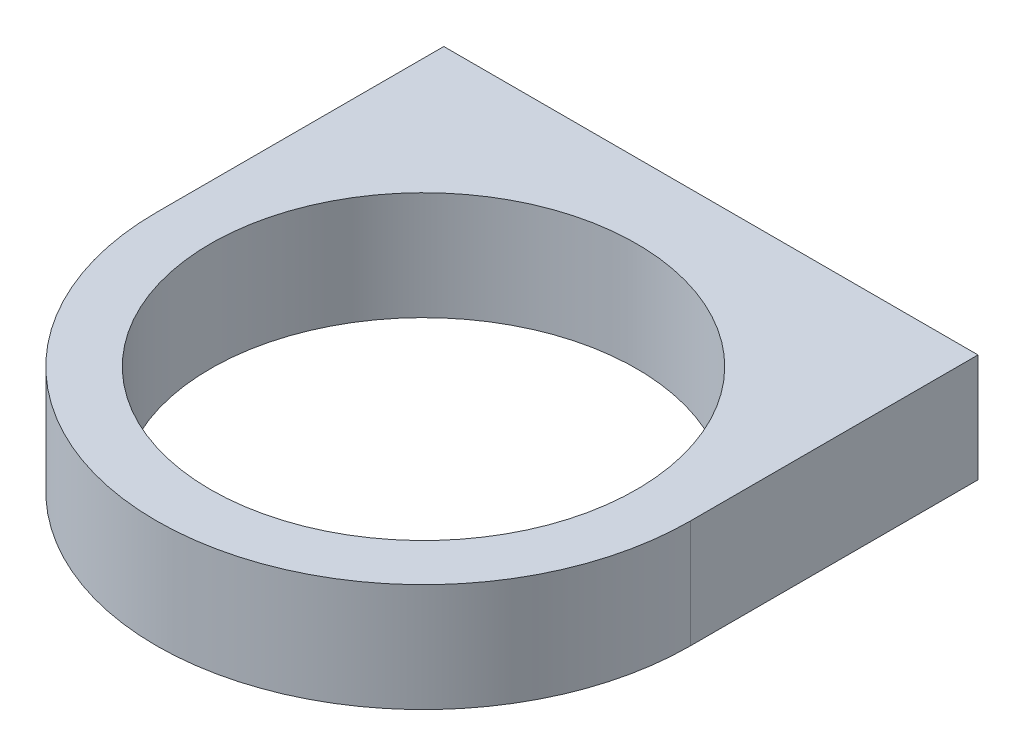
from build123d import *

# Parameters (mm, degrees)
SKETCH18_R           = 31.5
BOSS_EXTRUDE13_DEPTH = 16
SKETCH19_R           = 2
BOSS_EXTRUDE14_DEPTH = 2


with BuildPart() as part:
    # Sketch18 → Boss-Extrude13 (new body)
    with BuildSketch(Plane(origin=(0, 0, 0), x_dir=(1, 0, 0), z_dir=(0, 1, 0))):
        with BuildLine():
            Line((-39.5, 0), (-39.5, 42.5))
            Line((-39.5, 42.5), (39.5, 42.5))
            Line((39.5, 42.5), (39.5, 0))
            ThreePointArc((39.5, 0), (0, -39.5), (-39.5, 0))
        make_face()
        Circle(SKETCH18_R, mode=Mode.SUBTRACT)
    extrude(amount=BOSS_EXTRUDE13_DEPTH)

    # Sketch19 → Boss-Extrude14 (add)
    with BuildSketch(Plane.XZ):
        with Locations((-35.5, -38.5)):
            Circle(SKETCH19_R)
        with Locations((35.5, -38.5)):
            Circle(SKETCH19_R)
    extrude(amount=BOSS_EXTRUDE14_DEPTH)


solid = part.part
